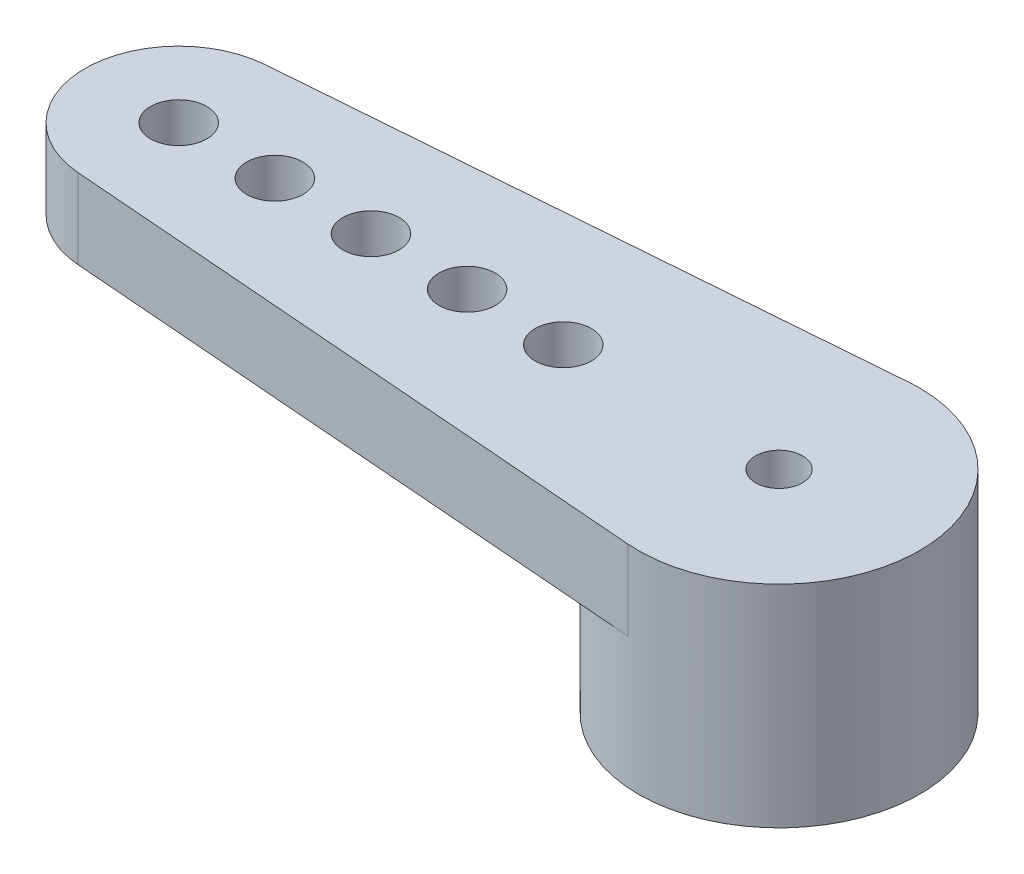
from build123d import *

# Parameters (mm, degrees)
BOSS_EXTRUDE1_DEPTH = 1.7
SKETCH2_R           = 0.6
CUT_EXTRUDE1_DEPTH  = 2.7
SKETCH3_R           = 3
BOSS_EXTRUDE2_DEPTH = 2.8
SKETCH4_R           = 0.5
CUT_EXTRUDE2_DEPTH  = 5.5


with BuildPart() as part:
    # Sketch1 → Boss-Extrude1 (new body)
    with BuildSketch(Plane(origin=(0, 0, 0), x_dir=(1, 0, 0), z_dir=(0, 1, 0))):
        with BuildLine():
            Line((-3, 0), (-10.8, 0))
            ThreePointArc((-10.8, 0), (-11.442152439, -1.468417516), (-12.95625, -1.993887143))
            Line((-12.95625, -1.993887143), (-0.234375, -2.990830714))
            ThreePointArc((-0.234375, -2.990830714), (-2.202626273, -2.036771342), (-3, 0))
        make_face()
        with BuildLine():
            ThreePointArc((-12.95625, 1.993887143), (-14.268417516, 1.357847561), (-14.8, 0))
            Line((-14.8, 0), (-10.8, 0))
            ThreePointArc((-10.8, 0), (-11.442152439, 1.468417516), (-12.95625, 1.993887143))
        make_face()
        with BuildLine():
            Line((-10.8, 0), (-14.8, 0))
            ThreePointArc((-14.8, 0), (-14.268417516, -1.357847561), (-12.95625, -1.993887143))
            ThreePointArc((-12.95625, -1.993887143), (-11.442152439, -1.468417516), (-10.8, 0))
        make_face()
        with BuildLine():
            ThreePointArc((-12.95625, 1.993887143), (-11.442152439, 1.468417516), (-10.8, 0))
            Line((-10.8, 0), (-3, 0))
            ThreePointArc((-3, 0), (-2.202626273, 2.036771342), (-0.234375, 2.990830714))
            Line((-0.234375, 2.990830714), (-12.95625, 1.993887143))
        make_face()
        with BuildLine():
            ThreePointArc((-0.234375, 2.990830714), (-2.202626273, 2.036771342), (-3, 0))
            Line((-3, 0), (3, 0))
            ThreePointArc((3, 0), (2.036771342, 2.202626273), (-0.234375, 2.990830714))
        make_face()
        with BuildLine():
            Line((3, 0), (-3, 0))
            ThreePointArc((-3, 0), (-2.202626273, -2.036771342), (-0.234375, -2.990830714))
            ThreePointArc((-0.234375, -2.990830714), (2.036771342, -2.202626273), (3, 0))
        make_face()
    extrude(amount=BOSS_EXTRUDE1_DEPTH)

    # Sketch2 → Cut-Extrude1 (cut, through all)
    with BuildSketch(Plane(origin=(0, 1.7, 0), x_dir=(1, 0, 0), z_dir=(0, 1, 0))):
        with Locations((-12.8, 0)):
            Circle(SKETCH2_R)
        with Locations((-10.75, 0)):
            Circle(SKETCH2_R)
        with Locations((-8.7, 0)):
            Circle(SKETCH2_R)
        with Locations((-6.65, 0)):
            Circle(SKETCH2_R)
        with Locations((-4.6, 0)):
            Circle(SKETCH2_R)
    extrude(amount=-CUT_EXTRUDE1_DEPTH, mode=Mode.SUBTRACT)

    # Sketch3 → Boss-Extrude2 (add)
    with BuildSketch(Plane.XZ):
        Circle(SKETCH3_R)
    extrude(amount=BOSS_EXTRUDE2_DEPTH)

    # Sketch4 → Cut-Extrude2 (cut, through all)
    with BuildSketch(Plane.XZ.offset(2.8)):
        Circle(SKETCH4_R)
    extrude(amount=-CUT_EXTRUDE2_DEPTH, mode=Mode.SUBTRACT)


solid = part.part
